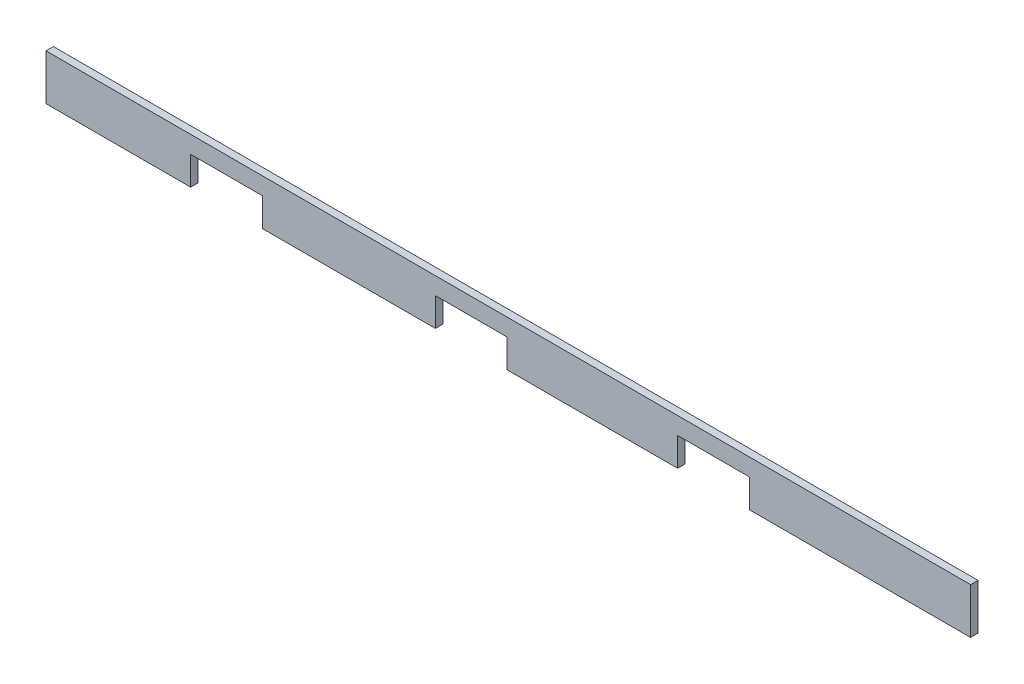
from build123d import *

# Parameters (mm, degrees)
BOSS_EXTRUDE1_DEPTH = 38.1


with BuildPart() as part:
    # Sketch1 → Boss-Extrude1 (new body)
    with BuildSketch(Plane.XY):
        Polygon((4749.8, 234.95), (0, 234.95), (0, 0), (742.95, 0), (742.95, 146.05), (1111.25, 146.05), (1111.25, 0), (2000.25, 0), (2000.25, 146.05), (2368.55, 146.05), (2368.55, 0), (3244.85, 0), (3244.85, 146.05), (3613.15, 146.05), (3613.15, 0), (4749.8, 0), align=None)
    extrude(amount=BOSS_EXTRUDE1_DEPTH)


solid = part.part
